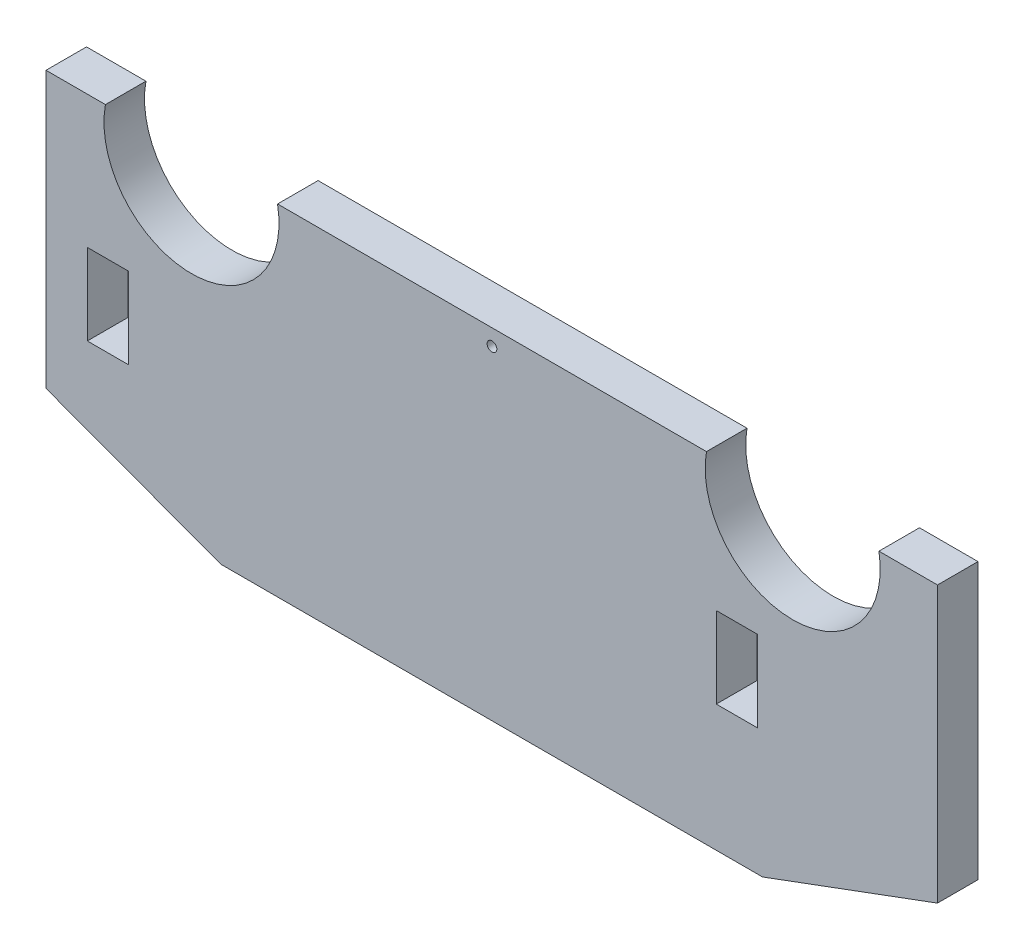
from build123d import *

# Parameters (mm, degrees)
SKETCH1_W                        = 69.85
SKETCH1_H                        = 19.05
MAIN_BODY_DEPTH                  = 3.175
CHIN_FEATURE_DEPTH               = 3.175
SKETCH10_W                       = 3.2258
SKETCH10_H                       = 6.35
CUT_FOR_TABS_DEPTH               = 4.175
CUT_FOR_LIP_MOTOR_APERTURE_DEPTH = 4.175
SKETCH12_R                       = 0.381
CUT_EXTRUDE1_DEPTH               = 4.175


with BuildPart() as part:
    # Sketch1 → main body (new body)
    with BuildSketch(Plane.XY):
        Rectangle(SKETCH1_W, SKETCH1_H)
    extrude(amount=MAIN_BODY_DEPTH)

    # Sketch9 → chin feature (add)
    with BuildSketch(Plane.XY.offset(3.175)):
        Polygon((-34.925, -9.525), (-34.925, -12.065), (-21.214947133, -17.145), (0, -17.145), (0, -9.525), align=None)
    chin_feature = extrude(amount=-CHIN_FEATURE_DEPTH)

    # mirror of chin feature: chin feature across plane
    add(chin_feature.mirror(Plane(origin=(0, 0, 0), x_dir=(0, 0, 1), z_dir=(1, 0, 0))))

    # Sketch10 → cut for tabs (cut, through all)
    with BuildSketch(Plane.XY.offset(3.175)):
        with Locations((-30.076100278, -4.050352196)):
            Rectangle(SKETCH10_W, SKETCH10_H)
        with Locations((19.20572281, -4.050352196)):
            Rectangle(SKETCH10_W, SKETCH10_H)
    extrude(amount=-CUT_FOR_TABS_DEPTH, mode=Mode.SUBTRACT)

    # Sketch11 → cut for lip motor aperture (cut, through all)
    with BuildSketch(Plane.XY.offset(3.175)):
        with BuildLine():
            Line((-23.576637278, 18.516146957), (-26.370637278, 18.516146957))
            Line((-26.370637278, 18.516146957), (-26.370637278, 14.520081328))
            ThreePointArc((-26.370637278, 14.520081328), (-23.470211189, 1.422172556), (-20.782637278, 14.565407781))
            Line((-20.782637278, 14.565407781), (-20.782637278, 18.516146957))
            Line((-20.782637278, 18.516146957), (-23.576637278, 18.516146957))
        make_face()
        with BuildLine():
            Line((23.530508447, 18.585729376), (20.736508447, 18.585729376))
            Line((20.736508447, 18.585729376), (20.736508447, 14.589663746))
            ThreePointArc((20.736508447, 14.589663746), (23.636934536, 1.491754974), (26.324508447, 14.634990199))
            Line((26.324508447, 14.634990199), (26.324508447, 18.585729376))
            Line((26.324508447, 18.585729376), (23.530508447, 18.585729376))
        make_face()
    extrude(amount=-CUT_FOR_LIP_MOTOR_APERTURE_DEPTH, mode=Mode.SUBTRACT)

    # Sketch12 → Cut-Extrude1 (cut, through all)
    with BuildSketch(Plane.XY.offset(3.175)):
        with Locations((0.018631462, 8.255)):
            Circle(SKETCH12_R)
    extrude(amount=-CUT_EXTRUDE1_DEPTH, mode=Mode.SUBTRACT)


solid = part.part
